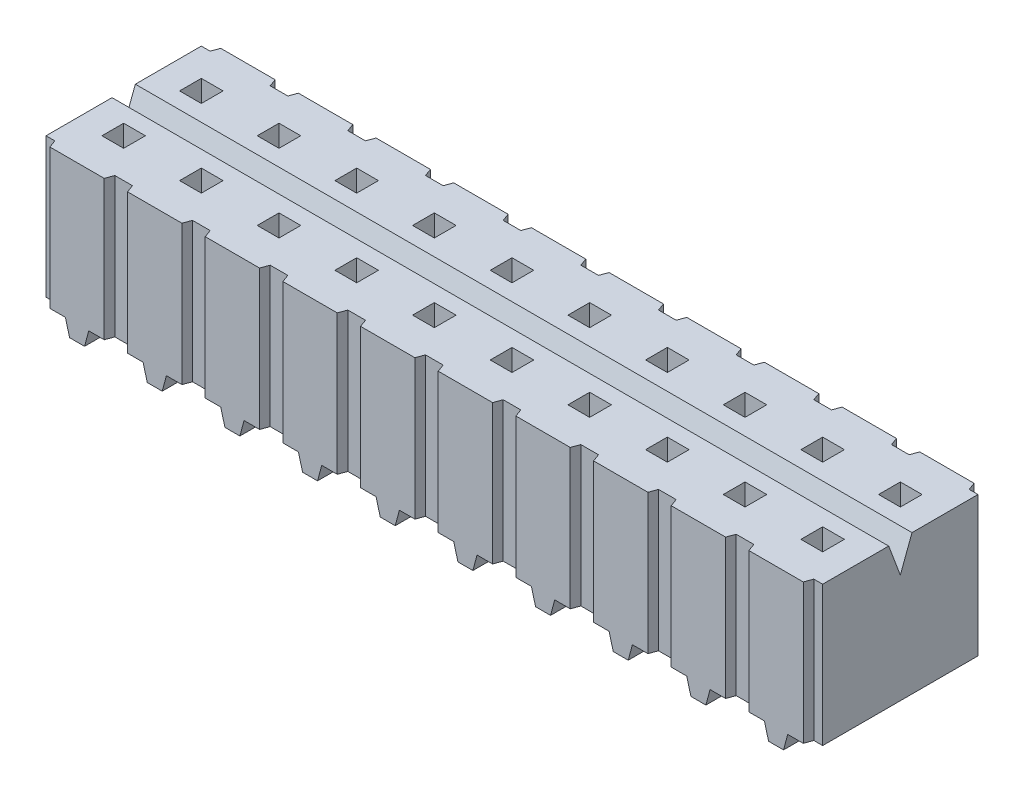
from build123d import *

# Parameters (mm, degrees)
BOSS_EXTRUDE1_DEPTH  = 4.572
DRAFT1_ANGLE         = 20
DRAFT2_ANGLE         = 20
DRAFT3_ANGLE         = 20
DRAFT4_ANGLE         = 20
DRAFT5_ANGLE         = 20
DRAFT6_ANGLE         = 20
DRAFT7_ANGLE         = 20
DRAFT8_ANGLE         = 20
DRAFT9_ANGLE         = 20
DRAFT10_ANGLE        = 20
DRAFT11_ANGLE        = 20
DRAFT12_ANGLE        = 20
DRAFT13_ANGLE        = 20
DRAFT14_ANGLE        = 20
DRAFT15_ANGLE        = 20
DRAFT16_ANGLE        = 20
DRAFT17_ANGLE        = 20
DRAFT18_ANGLE        = 20
DRAFT19_ANGLE        = 20
DRAFT20_ANGLE        = 20
SKETCH2_W            = 0.762
SKETCH2_H            = 0.508
BOSS_EXTRUDE2_DEPTH  = 0.508
SKETCH3_W            = 0.762
SKETCH3_H            = 0.508
BOSS_EXTRUDE3_DEPTH  = 0.508
SKETCH4_W            = 0.762
SKETCH4_H            = 0.508
BOSS_EXTRUDE4_DEPTH  = 0.508
SKETCH5_W            = 0.762
SKETCH5_H            = 0.508
BOSS_EXTRUDE5_DEPTH  = 0.508
SKETCH6_W            = 0.762
SKETCH6_H            = 0.508
BOSS_EXTRUDE6_DEPTH  = 0.508
SKETCH7_W            = 0.762
SKETCH7_H            = 0.508
BOSS_EXTRUDE7_DEPTH  = 0.508
SKETCH8_W            = 0.762
SKETCH8_H            = 0.508
BOSS_EXTRUDE8_DEPTH  = 0.508
SKETCH9_W            = 0.762
SKETCH9_H            = 0.508
BOSS_EXTRUDE9_DEPTH  = 0.508
SKETCH10_W           = 0.762
SKETCH10_H           = 0.508
BOSS_EXTRUDE10_DEPTH = 0.508
SKETCH11_W           = 0.762
SKETCH11_H           = 0.508
BOSS_EXTRUDE11_DEPTH = 0.508
SKETCH12_W           = 0.762
SKETCH12_H           = 0.508
BOSS_EXTRUDE12_DEPTH = 0.508
SKETCH13_W           = 0.762
SKETCH13_H           = 0.508
BOSS_EXTRUDE13_DEPTH = 0.508
SKETCH14_W           = 0.762
SKETCH14_H           = 0.508
BOSS_EXTRUDE14_DEPTH = 0.508
SKETCH15_W           = 0.762
SKETCH15_H           = 0.508
BOSS_EXTRUDE15_DEPTH = 0.508
SKETCH16_W           = 0.762
SKETCH16_H           = 0.508
BOSS_EXTRUDE16_DEPTH = 0.508
SKETCH17_W           = 0.762
SKETCH17_H           = 0.508
BOSS_EXTRUDE17_DEPTH = 0.508
SKETCH18_W           = 0.762
SKETCH18_H           = 0.508
BOSS_EXTRUDE18_DEPTH = 0.508
SKETCH19_W           = 0.762
SKETCH19_H           = 0.508
BOSS_EXTRUDE19_DEPTH = 0.508
SKETCH20_W           = 0.762
SKETCH20_H           = 0.508
BOSS_EXTRUDE20_DEPTH = 0.508
SKETCH21_W           = 0.762
SKETCH21_H           = 0.508
BOSS_EXTRUDE21_DEPTH = 0.508
DRAFT21_ANGLE        = 15
CUT_EXTRUDE1_DEPTH   = 26.4
SKETCH23_W           = 0.7112
SKETCH23_H           = 0.7112
CUT_EXTRUDE2_DEPTH   = 4.318
SKETCH24_W           = 0.7112
SKETCH24_H           = 0.7112
CUT_EXTRUDE3_DEPTH   = 4.318
SKETCH25_W           = 0.7112
SKETCH25_H           = 0.7112
CUT_EXTRUDE4_DEPTH   = 4.318
SKETCH26_W           = 0.7112
SKETCH26_H           = 0.7112
CUT_EXTRUDE5_DEPTH   = 4.318
SKETCH27_W           = 0.7112
SKETCH27_H           = 0.7112
CUT_EXTRUDE6_DEPTH   = 4.318
SKETCH28_W           = 0.7112
SKETCH28_H           = 0.7112
CUT_EXTRUDE7_DEPTH   = 4.318
SKETCH29_W           = 0.7112
SKETCH29_H           = 0.7112
CUT_EXTRUDE8_DEPTH   = 4.318
SKETCH30_W           = 0.7112
SKETCH30_H           = 0.7112
CUT_EXTRUDE9_DEPTH   = 4.318
SKETCH31_W           = 0.7112
SKETCH31_H           = 0.7112
CUT_EXTRUDE10_DEPTH  = 4.318
SKETCH32_W           = 0.7112
SKETCH32_H           = 0.7112
CUT_EXTRUDE11_DEPTH  = 4.318
SKETCH33_W           = 0.7112
SKETCH33_H           = 0.7112
CUT_EXTRUDE12_DEPTH  = 4.318
SKETCH34_W           = 0.7112
SKETCH34_H           = 0.7112
CUT_EXTRUDE13_DEPTH  = 4.318
SKETCH35_W           = 0.7112
SKETCH35_H           = 0.7112
CUT_EXTRUDE14_DEPTH  = 4.318
SKETCH36_W           = 0.7112
SKETCH36_H           = 0.7112
CUT_EXTRUDE15_DEPTH  = 4.318
SKETCH37_W           = 0.7112
SKETCH37_H           = 0.7112
CUT_EXTRUDE16_DEPTH  = 4.318
SKETCH38_W           = 0.7112
SKETCH38_H           = 0.7112
CUT_EXTRUDE17_DEPTH  = 4.318
SKETCH39_W           = 0.7112
SKETCH39_H           = 0.7112
CUT_EXTRUDE18_DEPTH  = 4.318
SKETCH40_W           = 0.7112
SKETCH40_H           = 0.7112
CUT_EXTRUDE19_DEPTH  = 4.318
SKETCH41_W           = 0.7112
SKETCH41_H           = 0.7112
CUT_EXTRUDE20_DEPTH  = 4.318
SKETCH42_W           = 0.7112
SKETCH42_H           = 0.7112
CUT_EXTRUDE21_DEPTH  = 4.318


with BuildPart() as part:
    # Sketch1 → Boss-Extrude1 (new body)
    with BuildSketch(Plane.XZ.offset(-0.508)):
        Polygon((-12.319, -2.794), (-10.541, -2.794), (-10.541, -2.54), (-9.779, -2.54), (-9.779, -2.794), (-8.001, -2.794), (-8.001, -2.54), (-7.239, -2.54), (-7.239, -2.794), (-5.461, -2.794), (-5.461, -2.54), (-4.699, -2.54), (-4.699, -2.794), (-2.921, -2.794), (-2.921, -2.54), (-2.159, -2.54), (-2.159, -2.794), (-0.381, -2.794), (-0.381, -2.54), (0.381, -2.54), (0.381, -2.794), (2.159, -2.794), (2.159, -2.54), (2.921, -2.54), (2.921, -2.794), (4.699, -2.794), (4.699, -2.54), (5.461, -2.54), (5.461, -2.794), (7.239, -2.794), (7.239, -2.54), (8.001, -2.54), (8.001, -2.794), (9.779, -2.794), (9.779, -2.54), (10.541, -2.54), (10.541, -2.794), (12.319, -2.794), (12.319, -2.54), (12.7, -2.54), (12.7, 2.54), (12.319, 2.54), (12.319, 2.794), (10.541, 2.794), (10.541, 2.54), (9.779, 2.54), (9.779, 2.794), (8.001, 2.794), (8.001, 2.54), (7.239, 2.54), (7.239, 2.794), (5.461, 2.794), (5.461, 2.54), (4.699, 2.54), (4.699, 2.794), (2.921, 2.794), (2.921, 2.54), (2.159, 2.54), (2.159, 2.794), (0.381, 2.794), (0.381, 2.54), (-0.381, 2.54), (-0.381, 2.794), (-2.159, 2.794), (-2.159, 2.54), (-2.921, 2.54), (-2.921, 2.794), (-4.699, 2.794), (-4.699, 2.54), (-5.461, 2.54), (-5.461, 2.794), (-7.239, 2.794), (-7.239, 2.54), (-8.001, 2.54), (-8.001, 2.794), (-9.779, 2.794), (-9.779, 2.54), (-10.541, 2.54), (-10.541, 2.794), (-12.319, 2.794), (-12.319, 2.54), (-12.7, 2.54), (-12.7, -2.54), (-12.319, -2.54), align=None)
    extrude(amount=-BOSS_EXTRUDE1_DEPTH)

    # Draft1
    draft1_faces = [part.faces().sort_by_distance(p)[0] for p in [
        (-12.319, 2.794, -2.667),
        (-10.541, 2.794, -2.667),
    ]]
    draft(draft1_faces, Plane(origin=(-12.319, 5.08, -2.794), x_dir=(-1, 0, 0), z_dir=(0, 0, -1)), DRAFT1_ANGLE)

    # Draft2
    draft2_faces = [part.faces().sort_by_distance(p)[0] for p in [
        (-9.779, 2.794, -2.667),
        (-8.001, 2.794, -2.667),
    ]]
    draft(draft2_faces, Plane(origin=(-9.779, 5.08, -2.794), x_dir=(-1, 0, 0), z_dir=(0, 0, -1)), DRAFT2_ANGLE)

    # Draft3
    draft3_faces = [part.faces().sort_by_distance(p)[0] for p in [
        (-7.239, 2.794, -2.667),
        (-5.461, 2.794, -2.667),
    ]]
    draft(draft3_faces, Plane(origin=(-7.239, 5.08, -2.794), x_dir=(-1, 0, 0), z_dir=(0, 0, -1)), DRAFT3_ANGLE)

    # Draft4
    draft4_faces = [part.faces().sort_by_distance(p)[0] for p in [
        (-4.699, 2.794, -2.667),
        (-2.921, 2.794, -2.667),
    ]]
    draft(draft4_faces, Plane(origin=(-4.699, 5.08, -2.794), x_dir=(-1, 0, 0), z_dir=(0, 0, -1)), DRAFT4_ANGLE)

    # Draft5
    draft5_faces = [part.faces().sort_by_distance(p)[0] for p in [
        (-2.159, 2.794, -2.667),
        (-0.381, 2.794, -2.667),
    ]]
    draft(draft5_faces, Plane(origin=(-2.159, 5.08, -2.794), x_dir=(-1, 0, 0), z_dir=(0, 0, -1)), DRAFT5_ANGLE)

    # Draft6
    draft6_faces = [part.faces().sort_by_distance(p)[0] for p in [
        (0.381, 2.794, -2.667),
        (2.159, 2.794, -2.667),
    ]]
    draft(draft6_faces, Plane(origin=(0.381, 5.08, -2.794), x_dir=(-1, 0, 0), z_dir=(0, 0, -1)), DRAFT6_ANGLE)

    # Draft7
    draft7_faces = [part.faces().sort_by_distance(p)[0] for p in [
        (2.921, 2.794, -2.667),
        (4.699, 2.794, -2.667),
    ]]
    draft(draft7_faces, Plane(origin=(2.921, 5.08, -2.794), x_dir=(-1, 0, 0), z_dir=(0, 0, -1)), DRAFT7_ANGLE)

    # Draft8
    draft8_faces = [part.faces().sort_by_distance(p)[0] for p in [
        (5.461, 2.794, -2.667),
        (7.239, 2.794, -2.667),
    ]]
    draft(draft8_faces, Plane(origin=(5.461, 5.08, -2.794), x_dir=(-1, 0, 0), z_dir=(0, 0, -1)), DRAFT8_ANGLE)

    # Draft9
    draft9_faces = [part.faces().sort_by_distance(p)[0] for p in [
        (8.001, 2.794, -2.667),
        (9.779, 2.794, -2.667),
    ]]
    draft(draft9_faces, Plane(origin=(8.001, 5.08, -2.794), x_dir=(-1, 0, 0), z_dir=(0, 0, -1)), DRAFT9_ANGLE)

    # Draft10
    draft10_faces = [part.faces().sort_by_distance(p)[0] for p in [
        (10.541, 2.794, -2.667),
        (12.319, 2.794, -2.667),
    ]]
    draft(draft10_faces, Plane(origin=(10.541, 5.08, -2.794), x_dir=(-1, 0, 0), z_dir=(0, 0, -1)), DRAFT10_ANGLE)

    # Draft11
    draft11_faces = [part.faces().sort_by_distance(p)[0] for p in [
        (-10.541, 2.794, 2.667),
        (-12.319, 2.794, 2.667),
    ]]
    draft(draft11_faces, Plane(origin=(-10.541, 5.08, 2.794), x_dir=(1, 0, 0), z_dir=(0, 0, 1)), DRAFT11_ANGLE)

    # Draft12
    draft12_faces = [part.faces().sort_by_distance(p)[0] for p in [
        (-8.001, 2.794, 2.667),
        (-9.779, 2.794, 2.667),
    ]]
    draft(draft12_faces, Plane(origin=(-8.001, 5.08, 2.794), x_dir=(1, 0, 0), z_dir=(0, 0, 1)), DRAFT12_ANGLE)

    # Draft13
    draft13_faces = [part.faces().sort_by_distance(p)[0] for p in [
        (-5.461, 2.794, 2.667),
        (-7.239, 2.794, 2.667),
    ]]
    draft(draft13_faces, Plane(origin=(-5.461, 5.08, 2.794), x_dir=(1, 0, 0), z_dir=(0, 0, 1)), DRAFT13_ANGLE)

    # Draft14
    draft14_faces = [part.faces().sort_by_distance(p)[0] for p in [
        (-2.921, 2.794, 2.667),
        (-4.699, 2.794, 2.667),
    ]]
    draft(draft14_faces, Plane(origin=(-2.921, 5.08, 2.794), x_dir=(1, 0, 0), z_dir=(0, 0, 1)), DRAFT14_ANGLE)

    # Draft15
    draft15_faces = [part.faces().sort_by_distance(p)[0] for p in [
        (-0.381, 2.794, 2.667),
        (-2.159, 2.794, 2.667),
    ]]
    draft(draft15_faces, Plane(origin=(-0.381, 5.08, 2.794), x_dir=(1, 0, 0), z_dir=(0, 0, 1)), DRAFT15_ANGLE)

    # Draft16
    draft16_faces = [part.faces().sort_by_distance(p)[0] for p in [
        (2.159, 2.794, 2.667),
        (0.381, 2.794, 2.667),
    ]]
    draft(draft16_faces, Plane(origin=(2.159, 5.08, 2.794), x_dir=(1, 0, 0), z_dir=(0, 0, 1)), DRAFT16_ANGLE)

    # Draft17
    draft17_faces = [part.faces().sort_by_distance(p)[0] for p in [
        (4.699, 2.794, 2.667),
        (2.921, 2.794, 2.667),
    ]]
    draft(draft17_faces, Plane(origin=(4.699, 5.08, 2.794), x_dir=(1, 0, 0), z_dir=(0, 0, 1)), DRAFT17_ANGLE)

    # Draft18
    draft18_faces = [part.faces().sort_by_distance(p)[0] for p in [
        (7.239, 2.794, 2.667),
        (5.461, 2.794, 2.667),
    ]]
    draft(draft18_faces, Plane(origin=(7.239, 5.08, 2.794), x_dir=(1, 0, 0), z_dir=(0, 0, 1)), DRAFT18_ANGLE)

    # Draft19
    draft19_faces = [part.faces().sort_by_distance(p)[0] for p in [
        (9.779, 2.794, 2.667),
        (8.001, 2.794, 2.667),
    ]]
    draft(draft19_faces, Plane(origin=(9.779, 5.08, 2.794), x_dir=(1, 0, 0), z_dir=(0, 0, 1)), DRAFT19_ANGLE)

    # Draft20
    draft20_faces = [part.faces().sort_by_distance(p)[0] for p in [
        (10.541, 2.794, 2.667),
        (12.319, 2.794, 2.667),
    ]]
    draft(draft20_faces, Plane(origin=(12.319, 5.08, 2.794), x_dir=(1, 0, 0), z_dir=(0, 0, 1)), DRAFT20_ANGLE)

    # Sketch2 → Boss-Extrude2 (add)
    with BuildSketch(Plane.XZ.offset(-0.508)):
        with Locations((-11.43, -2.54)):
            Rectangle(SKETCH2_W, SKETCH2_H)
    extrude(amount=BOSS_EXTRUDE2_DEPTH)

    # Sketch3 → Boss-Extrude3 (add)
    with BuildSketch(Plane.XZ.offset(-0.508)):
        with Locations((-8.89, -2.54)):
            Rectangle(SKETCH3_W, SKETCH3_H)
    extrude(amount=BOSS_EXTRUDE3_DEPTH)

    # Sketch4 → Boss-Extrude4 (add)
    with BuildSketch(Plane.XZ.offset(-0.508)):
        with Locations((-6.35, -2.54)):
            Rectangle(SKETCH4_W, SKETCH4_H)
    extrude(amount=BOSS_EXTRUDE4_DEPTH)

    # Sketch5 → Boss-Extrude5 (add)
    with BuildSketch(Plane.XZ.offset(-0.508)):
        with Locations((-3.81, -2.54)):
            Rectangle(SKETCH5_W, SKETCH5_H)
    extrude(amount=BOSS_EXTRUDE5_DEPTH)

    # Sketch6 → Boss-Extrude6 (add)
    with BuildSketch(Plane.XZ.offset(-0.508)):
        with Locations((-1.27, -2.54)):
            Rectangle(SKETCH6_W, SKETCH6_H)
    extrude(amount=BOSS_EXTRUDE6_DEPTH)

    # Sketch7 → Boss-Extrude7 (add)
    with BuildSketch(Plane.XZ.offset(-0.508)):
        with Locations((1.27, -2.54)):
            Rectangle(SKETCH7_W, SKETCH7_H)
    extrude(amount=BOSS_EXTRUDE7_DEPTH)

    # Sketch8 → Boss-Extrude8 (add)
    with BuildSketch(Plane.XZ.offset(-0.508)):
        with Locations((3.81, -2.54)):
            Rectangle(SKETCH8_W, SKETCH8_H)
    extrude(amount=BOSS_EXTRUDE8_DEPTH)

    # Sketch9 → Boss-Extrude9 (add)
    with BuildSketch(Plane.XZ.offset(-0.508)):
        with Locations((6.35, -2.54)):
            Rectangle(SKETCH9_W, SKETCH9_H)
    extrude(amount=BOSS_EXTRUDE9_DEPTH)

    # Sketch10 → Boss-Extrude10 (add)
    with BuildSketch(Plane.XZ.offset(-0.508)):
        with Locations((8.89, -2.54)):
            Rectangle(SKETCH10_W, SKETCH10_H)
    extrude(amount=BOSS_EXTRUDE10_DEPTH)

    # Sketch11 → Boss-Extrude11 (add)
    with BuildSketch(Plane.XZ.offset(-0.508)):
        with Locations((8.89, 2.54)):
            Rectangle(SKETCH11_W, SKETCH11_H)
    extrude(amount=BOSS_EXTRUDE11_DEPTH)

    # Sketch12 → Boss-Extrude12 (add)
    with BuildSketch(Plane.XZ.offset(-0.508)):
        with Locations((6.35, 2.54)):
            Rectangle(SKETCH12_W, SKETCH12_H)
    extrude(amount=BOSS_EXTRUDE12_DEPTH)

    # Sketch13 → Boss-Extrude13 (add)
    with BuildSketch(Plane.XZ.offset(-0.508)):
        with Locations((3.81, 2.54)):
            Rectangle(SKETCH13_W, SKETCH13_H)
    extrude(amount=BOSS_EXTRUDE13_DEPTH)

    # Sketch14 → Boss-Extrude14 (add)
    with BuildSketch(Plane.XZ.offset(-0.508)):
        with Locations((1.27, 2.54)):
            Rectangle(SKETCH14_W, SKETCH14_H)
    extrude(amount=BOSS_EXTRUDE14_DEPTH)

    # Sketch15 → Boss-Extrude15 (add)
    with BuildSketch(Plane.XZ.offset(-0.508)):
        with Locations((-1.27, 2.54)):
            Rectangle(SKETCH15_W, SKETCH15_H)
    extrude(amount=BOSS_EXTRUDE15_DEPTH)

    # Sketch16 → Boss-Extrude16 (add)
    with BuildSketch(Plane.XZ.offset(-0.508)):
        with Locations((-3.81, 2.54)):
            Rectangle(SKETCH16_W, SKETCH16_H)
    extrude(amount=BOSS_EXTRUDE16_DEPTH)

    # Sketch17 → Boss-Extrude17 (add)
    with BuildSketch(Plane.XZ.offset(-0.508)):
        with Locations((-6.35, 2.54)):
            Rectangle(SKETCH17_W, SKETCH17_H)
    extrude(amount=BOSS_EXTRUDE17_DEPTH)

    # Sketch18 → Boss-Extrude18 (add)
    with BuildSketch(Plane.XZ.offset(-0.508)):
        with Locations((-8.89, 2.54)):
            Rectangle(SKETCH18_W, SKETCH18_H)
    extrude(amount=BOSS_EXTRUDE18_DEPTH)

    # Sketch19 → Boss-Extrude19 (add)
    with BuildSketch(Plane.XZ.offset(-0.508)):
        with Locations((-11.43, 2.54)):
            Rectangle(SKETCH19_W, SKETCH19_H)
    extrude(amount=BOSS_EXTRUDE19_DEPTH)

    # Sketch20 → Boss-Extrude20 (add)
    with BuildSketch(Plane.XZ.offset(-0.508)):
        with Locations((11.43, 2.54)):
            Rectangle(SKETCH20_W, SKETCH20_H)
    extrude(amount=BOSS_EXTRUDE20_DEPTH)

    # Sketch21 → Boss-Extrude21 (add)
    with BuildSketch(Plane.XZ.offset(-0.508)):
        with Locations((11.43, -2.54)):
            Rectangle(SKETCH21_W, SKETCH21_H)
    extrude(amount=BOSS_EXTRUDE21_DEPTH)

    # Draft21
    draft21_faces = [part.faces().sort_by_distance(p)[0] for p in [
        (-11.049, 0.254, 2.54),
        (-8.509, 0.254, 2.54),
        (-5.969, 0.254, 2.54),
        (-3.429, 0.254, 2.54),
        (-0.889, 0.254, 2.54),
        (1.651, 0.254, 2.54),
        (4.191, 0.254, 2.54),
        (-11.049, 0.254, -2.54),
        (-8.509, 0.254, -2.54),
        (-5.969, 0.254, -2.54),
        (-3.429, 0.254, -2.54),
        (-0.889, 0.254, -2.54),
        (1.651, 0.254, -2.54),
        (4.191, 0.254, -2.54),
        (6.731, 0.254, 2.54),
        (6.731, 0.254, -2.54),
        (9.271, 0.254, 2.54),
        (9.271, 0.254, -2.54),
        (11.811, 0.254, 2.54),
        (11.811, 0.254, -2.54),
        (-9.271, 0.254, 2.54),
        (-6.731, 0.254, 2.54),
        (-4.191, 0.254, 2.54),
        (-1.651, 0.254, 2.54),
        (0.889, 0.254, 2.54),
        (3.429, 0.254, 2.54),
        (5.969, 0.254, 2.54),
        (8.509, 0.254, 2.54),
        (11.049, 0.254, 2.54),
        (11.049, 0.254, -2.54),
        (8.509, 0.254, -2.54),
        (5.969, 0.254, -2.54),
        (3.429, 0.254, -2.54),
        (0.889, 0.254, -2.54),
        (-1.651, 0.254, -2.54),
        (-4.191, 0.254, -2.54),
        (-6.731, 0.254, -2.54),
        (-9.271, 0.254, -2.54),
        (-11.811, 0.254, -2.54),
        (-11.811, 0.254, 2.54),
    ]]
    draft(draft21_faces, Plane(origin=(0, 0.508, 0), x_dir=(0, 0, -1), z_dir=(0, -1, 0)), DRAFT21_ANGLE)

    # Sketch22 → Cut-Extrude1 (cut, through all)
    with BuildSketch(Plane(origin=(12.7, 0, 0), x_dir=(0, 0, -1), z_dir=(1, 0, 0))):
        Polygon((0.381, 5.08), (-0.381, 5.08), (0, 4.064), align=None)
    extrude(amount=-CUT_EXTRUDE1_DEPTH, mode=Mode.SUBTRACT)

    # Sketch23 → Cut-Extrude2 (cut)
    with BuildSketch(Plane(origin=(0, 5.08, 0), x_dir=(-1, 0, 0), z_dir=(0, 1, 0))):
        with Locations((6.35, 1.27)):
            Rectangle(SKETCH23_W, SKETCH23_H)
    extrude(amount=-CUT_EXTRUDE2_DEPTH, mode=Mode.SUBTRACT)

    # Sketch24 → Cut-Extrude3 (cut)
    with BuildSketch(Plane(origin=(0, 5.08, 0), x_dir=(-1, 0, 0), z_dir=(0, 1, 0))):
        with Locations((3.81, 1.27)):
            Rectangle(SKETCH24_W, SKETCH24_H)
    extrude(amount=-CUT_EXTRUDE3_DEPTH, mode=Mode.SUBTRACT)

    # Sketch25 → Cut-Extrude4 (cut)
    with BuildSketch(Plane(origin=(0, 5.08, 0), x_dir=(-1, 0, 0), z_dir=(0, 1, 0))):
        with Locations((1.27, 1.27)):
            Rectangle(SKETCH25_W, SKETCH25_H)
    extrude(amount=-CUT_EXTRUDE4_DEPTH, mode=Mode.SUBTRACT)

    # Sketch26 → Cut-Extrude5 (cut)
    with BuildSketch(Plane(origin=(0, 5.08, 0), x_dir=(-1, 0, 0), z_dir=(0, 1, 0))):
        with Locations((-1.27, 1.27)):
            Rectangle(SKETCH26_W, SKETCH26_H)
    extrude(amount=-CUT_EXTRUDE5_DEPTH, mode=Mode.SUBTRACT)

    # Sketch27 → Cut-Extrude6 (cut)
    with BuildSketch(Plane(origin=(0, 5.08, 0), x_dir=(-1, 0, 0), z_dir=(0, 1, 0))):
        with Locations((-3.81, 1.27)):
            Rectangle(SKETCH27_W, SKETCH27_H)
    extrude(amount=-CUT_EXTRUDE6_DEPTH, mode=Mode.SUBTRACT)

    # Sketch28 → Cut-Extrude7 (cut)
    with BuildSketch(Plane(origin=(0, 5.08, 0), x_dir=(-1, 0, 0), z_dir=(0, 1, 0))):
        with Locations((-6.35, 1.27)):
            Rectangle(SKETCH28_W, SKETCH28_H)
    extrude(amount=-CUT_EXTRUDE7_DEPTH, mode=Mode.SUBTRACT)

    # Sketch29 → Cut-Extrude8 (cut)
    with BuildSketch(Plane(origin=(0, 5.08, 0), x_dir=(-1, 0, 0), z_dir=(0, 1, 0))):
        with Locations((-8.89, 1.27)):
            Rectangle(SKETCH29_W, SKETCH29_H)
    extrude(amount=-CUT_EXTRUDE8_DEPTH, mode=Mode.SUBTRACT)

    # Sketch30 → Cut-Extrude9 (cut)
    with BuildSketch(Plane(origin=(0, 5.08, 0), x_dir=(-1, 0, 0), z_dir=(0, 1, 0))):
        with Locations((-11.43, 1.27)):
            Rectangle(SKETCH30_W, SKETCH30_H)
    extrude(amount=-CUT_EXTRUDE9_DEPTH, mode=Mode.SUBTRACT)

    # Sketch31 → Cut-Extrude10 (cut)
    with BuildSketch(Plane(origin=(0, 5.08, 0), x_dir=(-1, 0, 0), z_dir=(0, 1, 0))):
        with Locations((8.89, 1.27)):
            Rectangle(SKETCH31_W, SKETCH31_H)
    extrude(amount=-CUT_EXTRUDE10_DEPTH, mode=Mode.SUBTRACT)

    # Sketch32 → Cut-Extrude11 (cut)
    with BuildSketch(Plane(origin=(0, 5.08, 0), x_dir=(-1, 0, 0), z_dir=(0, 1, 0))):
        with Locations((11.43, 1.27)):
            Rectangle(SKETCH32_W, SKETCH32_H)
    extrude(amount=-CUT_EXTRUDE11_DEPTH, mode=Mode.SUBTRACT)

    # Sketch33 → Cut-Extrude12 (cut)
    with BuildSketch(Plane(origin=(0, 5.08, 0), x_dir=(-1, 0, 0), z_dir=(0, 1, 0))):
        with Locations((-11.43, -1.27)):
            Rectangle(SKETCH33_W, SKETCH33_H)
    extrude(amount=-CUT_EXTRUDE12_DEPTH, mode=Mode.SUBTRACT)

    # Sketch34 → Cut-Extrude13 (cut)
    with BuildSketch(Plane(origin=(0, 5.08, 0), x_dir=(-1, 0, 0), z_dir=(0, 1, 0))):
        with Locations((-8.89, -1.27)):
            Rectangle(SKETCH34_W, SKETCH34_H)
    extrude(amount=-CUT_EXTRUDE13_DEPTH, mode=Mode.SUBTRACT)

    # Sketch35 → Cut-Extrude14 (cut)
    with BuildSketch(Plane(origin=(0, 5.08, 0), x_dir=(-1, 0, 0), z_dir=(0, 1, 0))):
        with Locations((-6.35, -1.27)):
            Rectangle(SKETCH35_W, SKETCH35_H)
    extrude(amount=-CUT_EXTRUDE14_DEPTH, mode=Mode.SUBTRACT)

    # Sketch36 → Cut-Extrude15 (cut)
    with BuildSketch(Plane(origin=(0, 5.08, 0), x_dir=(-1, 0, 0), z_dir=(0, 1, 0))):
        with Locations((-3.81, -1.27)):
            Rectangle(SKETCH36_W, SKETCH36_H)
    extrude(amount=-CUT_EXTRUDE15_DEPTH, mode=Mode.SUBTRACT)

    # Sketch37 → Cut-Extrude16 (cut)
    with BuildSketch(Plane(origin=(0, 5.08, 0), x_dir=(-1, 0, 0), z_dir=(0, 1, 0))):
        with Locations((-1.27, -1.27)):
            Rectangle(SKETCH37_W, SKETCH37_H)
    extrude(amount=-CUT_EXTRUDE16_DEPTH, mode=Mode.SUBTRACT)

    # Sketch38 → Cut-Extrude17 (cut)
    with BuildSketch(Plane(origin=(0, 5.08, 0), x_dir=(-1, 0, 0), z_dir=(0, 1, 0))):
        with Locations((1.27, -1.27)):
            Rectangle(SKETCH38_W, SKETCH38_H)
    extrude(amount=-CUT_EXTRUDE17_DEPTH, mode=Mode.SUBTRACT)

    # Sketch39 → Cut-Extrude18 (cut)
    with BuildSketch(Plane(origin=(0, 5.08, 0), x_dir=(-1, 0, 0), z_dir=(0, 1, 0))):
        with Locations((3.81, -1.27)):
            Rectangle(SKETCH39_W, SKETCH39_H)
    extrude(amount=-CUT_EXTRUDE18_DEPTH, mode=Mode.SUBTRACT)

    # Sketch40 → Cut-Extrude19 (cut)
    with BuildSketch(Plane(origin=(0, 5.08, 0), x_dir=(-1, 0, 0), z_dir=(0, 1, 0))):
        with Locations((6.35, -1.27)):
            Rectangle(SKETCH40_W, SKETCH40_H)
    extrude(amount=-CUT_EXTRUDE19_DEPTH, mode=Mode.SUBTRACT)

    # Sketch41 → Cut-Extrude20 (cut)
    with BuildSketch(Plane(origin=(0, 5.08, 0), x_dir=(-1, 0, 0), z_dir=(0, 1, 0))):
        with Locations((8.89, -1.27)):
            Rectangle(SKETCH41_W, SKETCH41_H)
    extrude(amount=-CUT_EXTRUDE20_DEPTH, mode=Mode.SUBTRACT)

    # Sketch42 → Cut-Extrude21 (cut)
    with BuildSketch(Plane(origin=(0, 5.08, 0), x_dir=(-1, 0, 0), z_dir=(0, 1, 0))):
        with Locations((11.43, -1.27)):
            Rectangle(SKETCH42_W, SKETCH42_H)
    extrude(amount=-CUT_EXTRUDE21_DEPTH, mode=Mode.SUBTRACT)


solid = part.part
